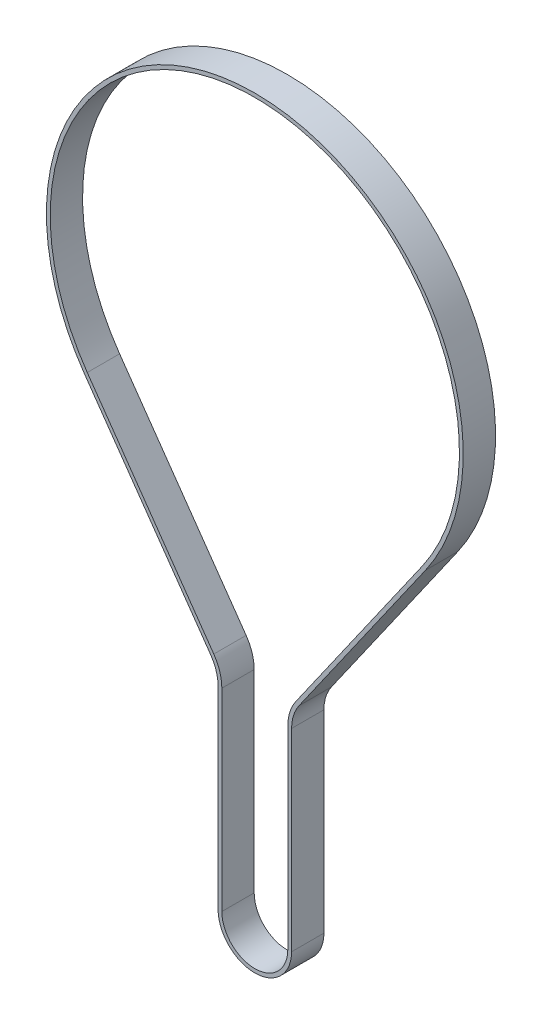
from build123d import *

# Parameters (mm, degrees)
BOSS_EXTRUDE1_DEPTH = 6


with BuildPart() as part:
    # Sketch2 → Boss-Extrude1 (new body)
    with BuildSketch(Plane.XY):
        with BuildLine():
            Line((-6.8162, 35.870699957), (-6.8162, 0))
            ThreePointArc((-6.8162, 0), (0, -6.8162), (6.8162, 0))
            Line((6.8162, 0), (6.8162, 35.870699957))
            ThreePointArc((6.8162, 35.870699957), (7.166039895, 38.142306097), (8.183138929, 40.203396091))
            Line((8.183138929, 40.203396091), (31.650065938, 73.692345781))
            ThreePointArc((31.650065938, 73.692345781), (0, 134.517899957), (-31.650065938, 73.692345781))
            Line((-31.650065938, 73.692345781), (-8.183138929, 40.203396091))
            ThreePointArc((-8.183138929, 40.203396091), (-7.166039895, 38.142306097), (-6.8162, 35.870699957))
        make_face()
        with BuildLine():
            Line((-6.1162, 35.870699957), (-6.1162, 0))
            ThreePointArc((-6.1162, 0), (0, -6.1162), (6.1162, 0))
            Line((6.1162, 0), (6.1162, 35.870699957))
            ThreePointArc((6.1162, 35.870699957), (6.498475381, 38.352918587), (7.609874988, 40.605103017))
            Line((7.609874988, 40.605103017), (31.076801998, 74.094052707))
            ThreePointArc((31.076801998, 74.094052707), (0, 133.817899957), (-31.076801998, 74.094052707))
            Line((-31.076801998, 74.094052707), (-7.609874988, 40.605103017))
            ThreePointArc((-7.609874988, 40.605103017), (-6.498475381, 38.352918587), (-6.1162, 35.870699957))
        make_face(mode=Mode.SUBTRACT)
    extrude(amount=BOSS_EXTRUDE1_DEPTH)


solid = part.part
